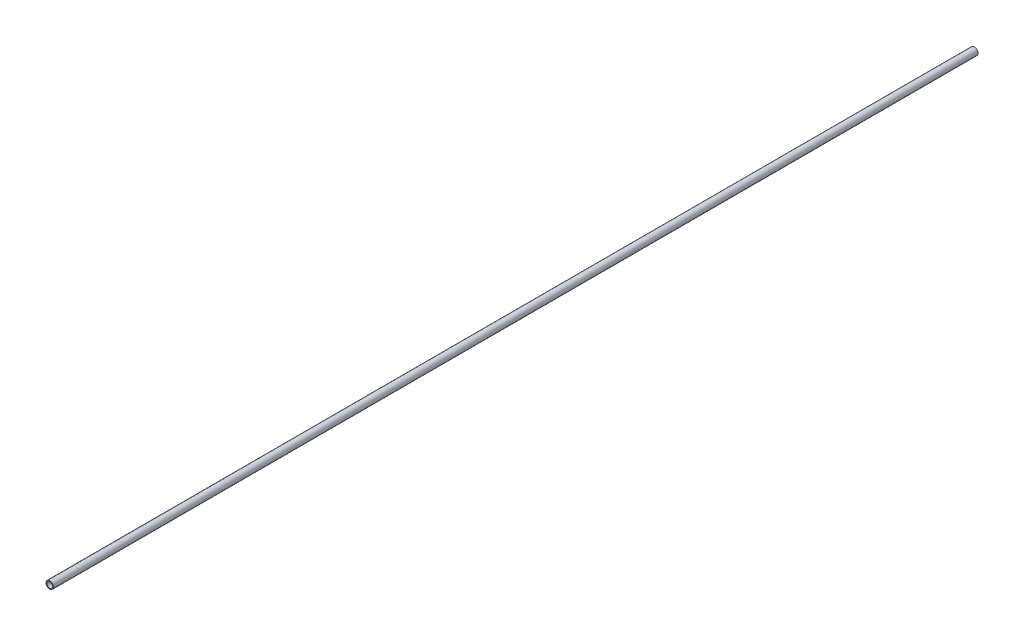
from build123d import *

# Parameters (mm, degrees)
SKETCH_1_R      = 4
SKETCH_1_R_2    = 3
EXTRUDE_1_DEPTH = 500


with BuildPart() as part:
    # Эскиз1 → Бобышка-Вытянуть1 (new body, symmetric)
    with BuildSketch(Plane.XY):
        Circle(SKETCH_1_R)
        Circle(SKETCH_1_R_2, mode=Mode.SUBTRACT)
    extrude(amount=EXTRUDE_1_DEPTH, both=True)


solid = part.part
